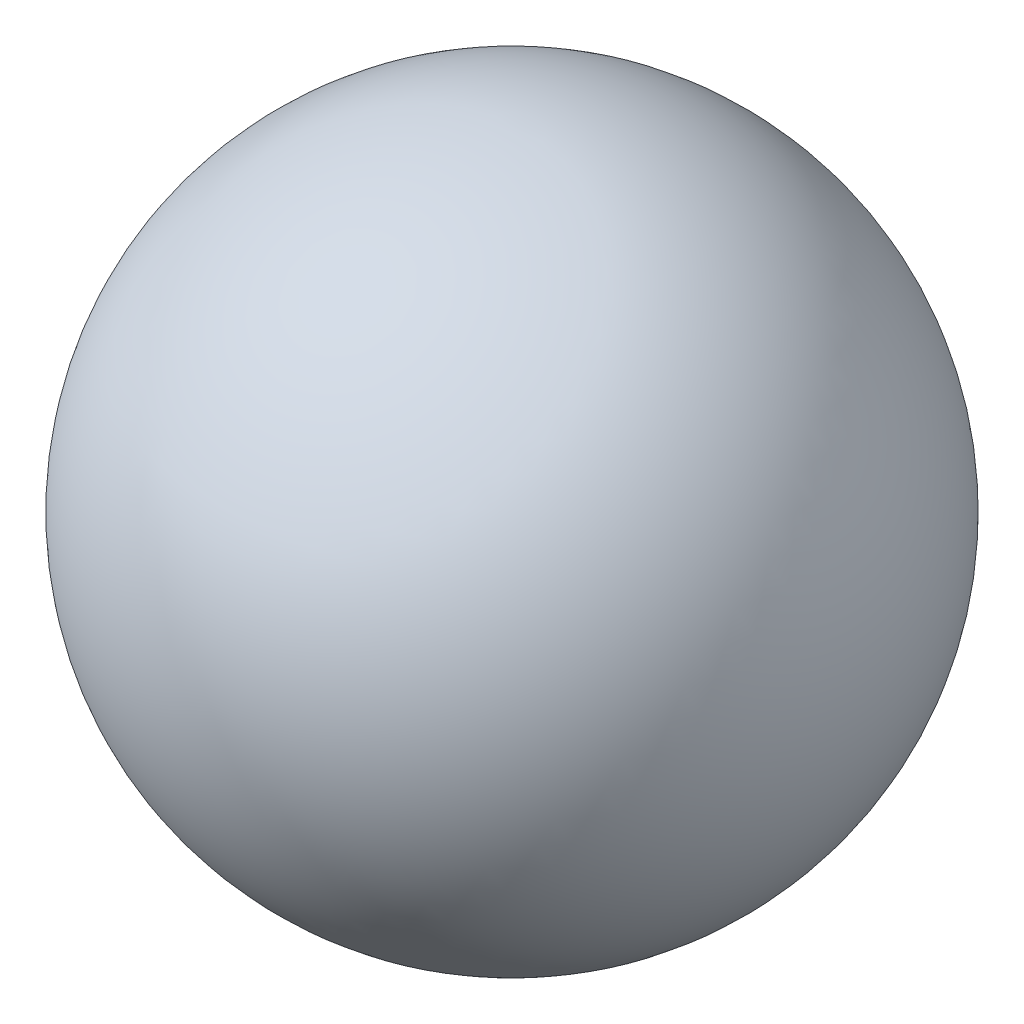
from build123d import *


with BuildPart() as part:
    # Croquis1 → Revolución10 (revolve)
    with BuildSketch(Plane.XY):
        with BuildLine():
            Line((0, 4.65), (0, -4.65))
            ThreePointArc((0, -4.65), (-4.65, 0), (0, 4.65))
        make_face()
    revolve(axis=Axis((0, 10.637642278, 0), (0, 1, 0)))


solid = part.part
